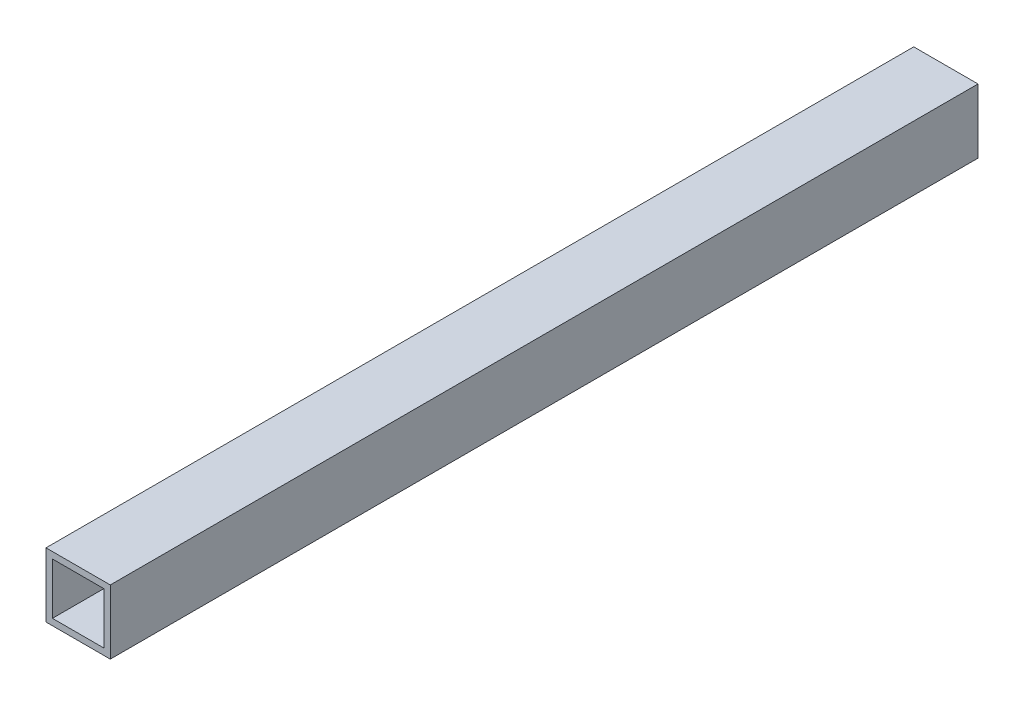
from build123d import *

# Parameters (mm, degrees)
SKETCH1_W      = 31.75
SKETCH1_H      = 31.75
SKETCH1_W_2    = 25.4
SKETCH1_H_2    = 25.4
EXTRUDE1_DEPTH = 428.625


with BuildPart() as part:
    # Sketch1 → Extrude1 (new body)
    with BuildSketch(Plane.XY):
        Rectangle(SKETCH1_W, SKETCH1_H)
        Rectangle(SKETCH1_W_2, SKETCH1_H_2, mode=Mode.SUBTRACT)
    extrude(amount=EXTRUDE1_DEPTH)


solid = part.part
